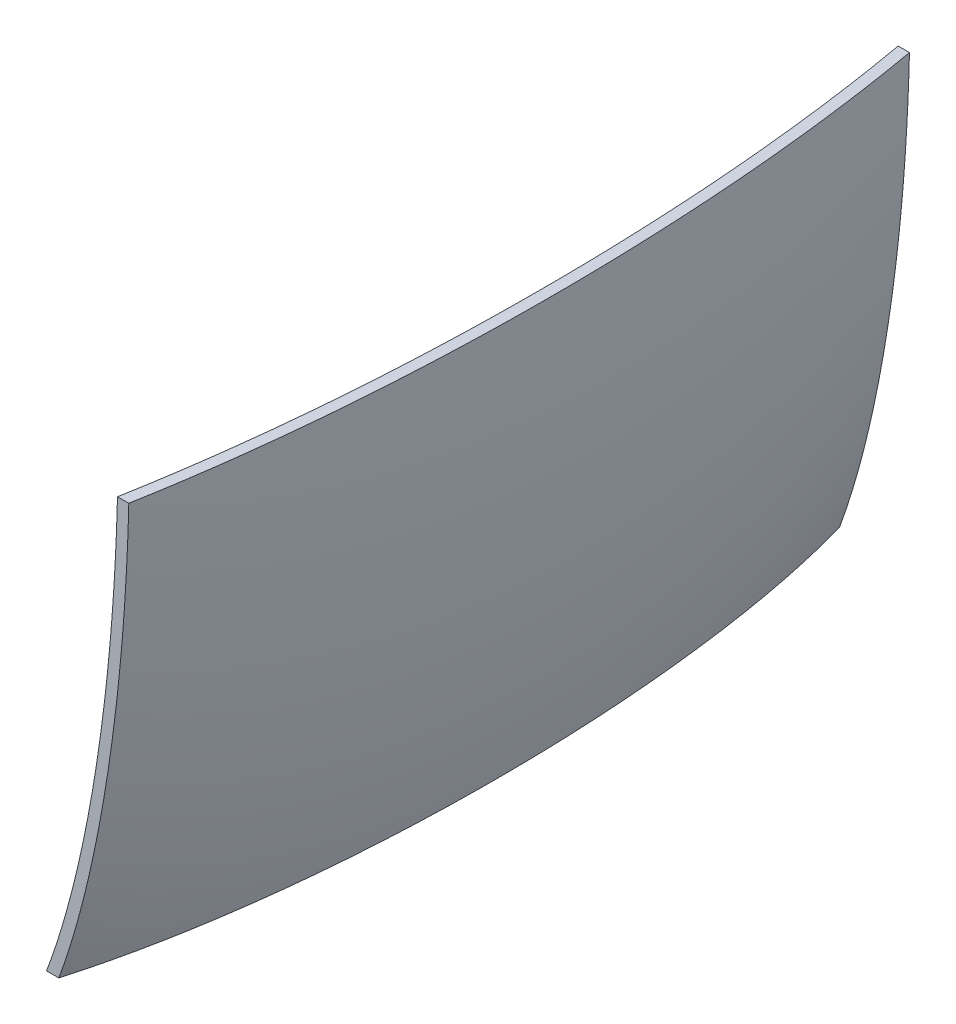
from build123d import *

# Parameters (mm, degrees)
SKETCH2_W               = 200
SKETCH2_H               = 200
SKETCH2_W_2             = 70
SKETCH2_H_2             = 40
CUT_EXTRUDE1_DEPTH      = 2.0000001
CUT_EXTRUDE1_DEPTH_BACK = 20.5580001


with BuildPart() as part:
    # Sketch1 → Revolve1 (revolve)
    with BuildSketch(Plane.XY):
        with BuildLine():
            Line((-19.558, -66.929), (-19.558, -67.929))
            add(Edge.make_bspline(
                [(-19.558, -67.929), (-18.802141164, -67.929), (-17.305164051, -67.673474135), (-14.442609506, -66.209360017), (-11.186515734, -62.7929565), (-7.698241079, -56.400320891), (-4.67619388, -47.906504938), (-2.208274357, -37.612295179), (-0.378616655, -25.896693359), (0.559130848, -15.314144608), (0.936828172, -6.600886267), (1, -2.196545793), (1, 0)],
                knots=[-3.141592654, -3.141592654, -3.141592654, -3.141592654, -3.043417883, -2.945243113, -2.748893572, -2.552544031, -2.35619449, -2.159844949, -1.963495408, -1.767145868, -1.668971097, -1.570796327, -1.570796327, -1.570796327, -1.570796327], degree=3))
            Line((1, 0), (0, 0))
            add(Edge.make_bspline(
                [(-19.558, -66.929), (0, -66.929), (0, 0)],
                knots=[3.141592654, 3.141592654, 3.141592654, 4.71238898, 4.71238898, 4.71238898], degree=2, weights=[1, 0.707106781, 1]))
        make_face()
    revolve(axis=Axis((-78.994, 0, 0), (1, 0, 0)))

    # Sketch2 → Cut-Extrude1 (cut, two sides)
    with BuildSketch(Plane(origin=(0, 0, 0), x_dir=(0, 0, -1), z_dir=(1, 0, 0))) as cut_extrude1_sk:
        Rectangle(SKETCH2_W, SKETCH2_H)
        with Locations((0, -25)):
            Rectangle(SKETCH2_W_2, SKETCH2_H_2, mode=Mode.SUBTRACT)
    extrude(amount=CUT_EXTRUDE1_DEPTH, mode=Mode.SUBTRACT)
    extrude(cut_extrude1_sk.sketch, amount=-CUT_EXTRUDE1_DEPTH_BACK, mode=Mode.SUBTRACT)


solid = part.part
